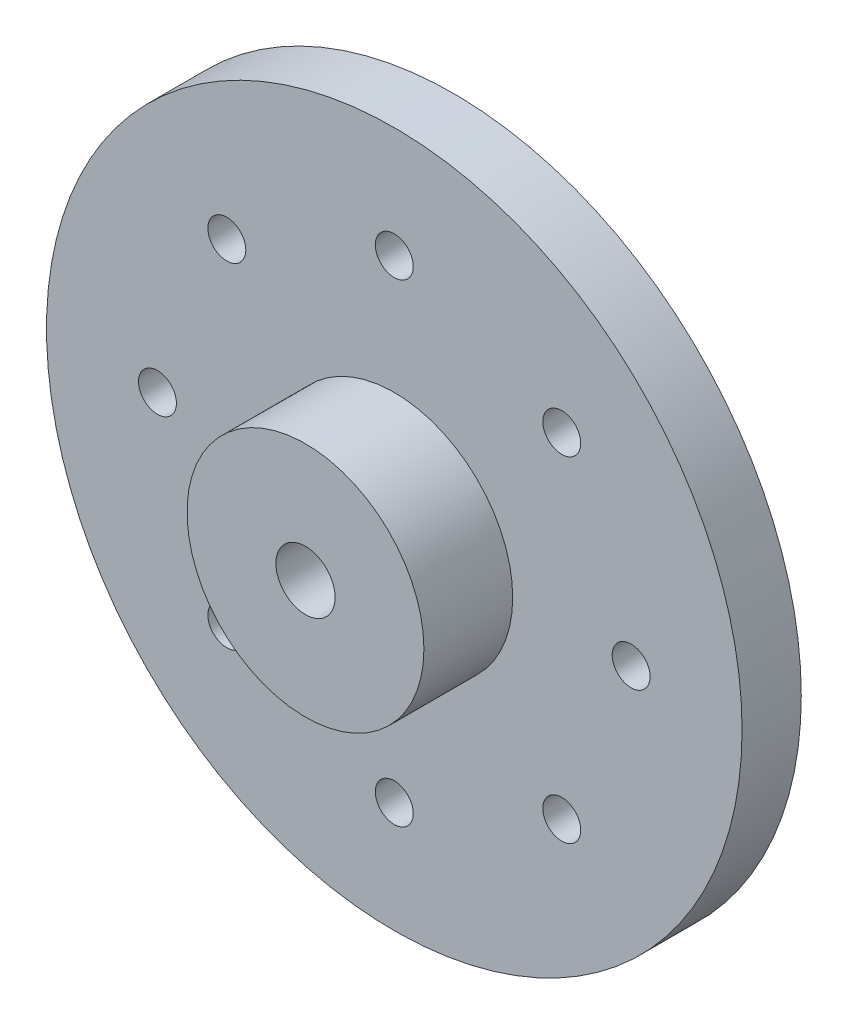
from build123d import *

# Parameters (mm, degrees)
SKETCH1_R           = 11.747376147
SKETCH1_R_2         = 2.669858215
SKETCH1_R_3         = 0.640765972
BOSS_EXTRUDE1_DEPTH = 2
SKETCH2_R           = 4
SKETCH2_R_2         = 1
BOSS_EXTRUDE2_DEPTH = 3
SKETCH3_R           = 4
SKETCH3_R_2         = 2.669858215
BOSS_EXTRUDE3_DEPTH = 1
CHAMFER1_SIZE       = 0.6


with BuildPart() as part:
    # Sketch1 → Boss-Extrude1 (new body)
    with BuildSketch(Plane.XY):
        Circle(SKETCH1_R)
        Circle(SKETCH1_R_2, mode=Mode.SUBTRACT)
        with Locations((0, 8)):
            Circle(SKETCH1_R_3, mode=Mode.SUBTRACT)
        with Locations((5.656854249, 5.656854249)):
            Circle(SKETCH1_R_3, mode=Mode.SUBTRACT)
        with Locations((8, 0)):
            Circle(SKETCH1_R_3, mode=Mode.SUBTRACT)
        with Locations((5.656854249, -5.656854249)):
            Circle(SKETCH1_R_3, mode=Mode.SUBTRACT)
        with Locations((0, -8)):
            Circle(SKETCH1_R_3, mode=Mode.SUBTRACT)
        with Locations((-5.656854249, -5.656854249)):
            Circle(SKETCH1_R_3, mode=Mode.SUBTRACT)
        with Locations((-8, 0)):
            Circle(SKETCH1_R_3, mode=Mode.SUBTRACT)
        with Locations((-5.656854249, 5.656854249)):
            Circle(SKETCH1_R_3, mode=Mode.SUBTRACT)
    extrude(amount=BOSS_EXTRUDE1_DEPTH)

    # Sketch2 → Boss-Extrude2 (add)
    with BuildSketch(Plane.XY.offset(2)):
        Circle(SKETCH2_R)
        Circle(SKETCH2_R_2, mode=Mode.SUBTRACT)
    extrude(amount=BOSS_EXTRUDE2_DEPTH)

    # Sketch3 → Boss-Extrude3 (add)
    with BuildSketch(Plane(origin=(0, 0, 0), x_dir=(-1, 0, 0), z_dir=(0, 0, -1))):
        Circle(SKETCH3_R)
        Circle(SKETCH3_R_2, mode=Mode.SUBTRACT)
    extrude(amount=BOSS_EXTRUDE3_DEPTH)

    # Chamfer1
    chamfer1_edges = [part.edges().sort_by_distance(p)[0] for p in [
        (4, 0, -1),
    ]]
    chamfer(chamfer1_edges, length=CHAMFER1_SIZE)


solid = part.part
